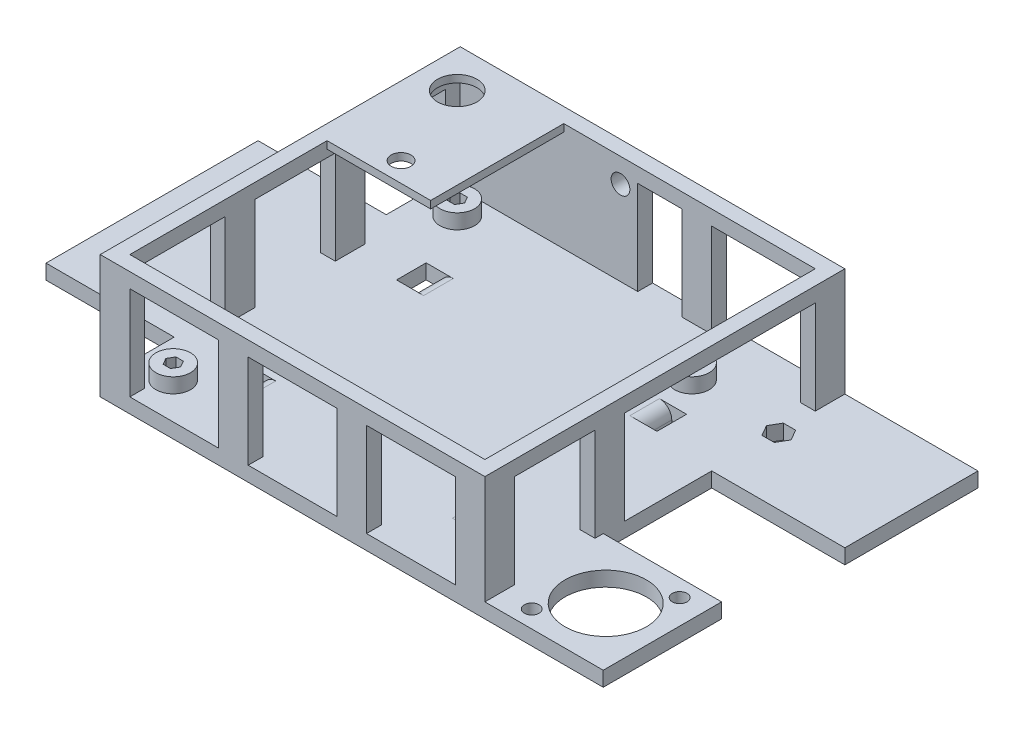
from build123d import *

# Parameters (mm, degrees)
BOSS_EXTRUDE1_DEPTH = 3
SKETCH2_W           = 3
SKETCH2_H           = 6
SKETCH2_W_2         = 6
SKETCH2_H_2         = 3
BOSS_EXTRUDE2_DEPTH = 19
SKETCH3_W           = 78
SKETCH3_H           = 73
SKETCH3_W_2         = 72
SKETCH3_H_2         = 67
BOSS_EXTRUDE3_DEPTH = 3
SKETCH4_R           = 3.5
BOSS_EXTRUDE4_DEPTH = 3
CUT_EXTRUDE1_DEPTH  = 130.761319352
CUT_EXTRUDE2_DEPTH  = 3
SKETCH7_R           = 1.9
CUT_EXTRUDE3_DEPTH  = 3
SKETCH8_W           = 21
SKETCH8_H           = 27
SKETCH8_R           = 2
SKETCH8_R_2         = 4
BOSS_EXTRUDE5_DEPTH = 1.5
SKETCH9_R           = 1.5
SKETCH9_R_2         = 8.25
CUT_EXTRUDE4_DEPTH  = 3
SKETCH10_W          = 3
SKETCH10_H          = 6
CUT_EXTRUDE5_DEPTH  = 3
FILLET1_R           = 2.5


with BuildPart() as part:
    # Sketch1 → Boss-Extrude1 (new body)
    with BuildSketch(Plane(origin=(0, 0, 0), x_dir=(1, 0, 0), z_dir=(0, 1, 0))):
        Polygon((100, 24), (102, 24), (102, 0), (100, 0), (78, 0), (0, 0), (0, 15), (-26, 15), (-26, 58), (0, 58), (0, 73), (78, 73), (105, 73), (105, 46), (78, 46), (78, 24), align=None)
    extrude(amount=BOSS_EXTRUDE1_DEPTH)

    # Sketch2 → Boss-Extrude2 (add)
    with BuildSketch(Plane(origin=(0, 3, 0), x_dir=(1, 0, 0), z_dir=(0, 1, 0))):
        Polygon((0, 0), (3, 0), (6, 0), (6, 3), (3, 3), (3, 6), (0, 6), align=None)
        Polygon((78, 0), (75, 0), (72, 0), (72, 3), (75, 3), (75, 6), (78, 6), align=None)
        with Locations((1.5, 25.3333)):
            Rectangle(SKETCH2_W, SKETCH2_H)
        with Locations((1.5, 47.6663)):
            Rectangle(SKETCH2_W, SKETCH2_H)
        Polygon((0, 73), (3, 73), (6, 73), (36, 73), (39, 73), (39, 70), (36, 70), (17, 70), (3, 70), (3, 67), (0, 67), align=None)
        with Locations((27, 1.5)):
            Rectangle(SKETCH2_W_2, SKETCH2_H_2)
        with Locations((51, 1.5)):
            Rectangle(SKETCH2_W_2, SKETCH2_H_2)
        with Locations((76.5, 25.333)):
            Rectangle(SKETCH2_W, SKETCH2_H)
        Polygon((72, 73), (78, 73), (78, 70), (78, 67), (75, 67), (75, 70), (72, 70), align=None)
        with Locations((51, 71.5)):
            Rectangle(SKETCH2_W_2, SKETCH2_H_2)
    extrude(amount=BOSS_EXTRUDE2_DEPTH)

    # Sketch3 → Boss-Extrude3 (add)
    with BuildSketch(Plane(origin=(0, 22, 0), x_dir=(1, 0, 0), z_dir=(0, 1, 0))):
        with Locations((39, 36.5)):
            Rectangle(SKETCH3_W, SKETCH3_H)
        with Locations((39, 36.5)):
            Rectangle(SKETCH3_W_2, SKETCH3_H_2, mode=Mode.SUBTRACT)
    extrude(amount=BOSS_EXTRUDE3_DEPTH)

    # Sketch4 → Boss-Extrude4 (add)
    # profile 1 of 4: a face of its own
    with BuildSketch(Plane(origin=(0, 3, 0), x_dir=(1, 0, 0), z_dir=(0, 1, 0))):
        with Locations((7.4, 65)):
            Circle(SKETCH4_R)
        Polygon((8.9, 65), (8.15, 66.299038106), (6.65, 66.299038106), (5.9, 65), (6.65, 63.700961894), (8.15, 63.700961894), align=None, mode=Mode.SUBTRACT)
    # profile 2 of 4: a face of its own
    with BuildSketch(Plane(origin=(0, 3, 0), x_dir=(1, 0, 0), z_dir=(0, 1, 0))):
        with Locations((7.4, 7.4)):
            Circle(SKETCH4_R)
        Polygon((8.9, 7.4), (8.15, 8.699038106), (6.65, 8.699038106), (5.9, 7.4), (6.65, 6.100961894), (8.15, 6.100961894), align=None, mode=Mode.SUBTRACT)
    # profile 3 of 4: a face of its own
    with BuildSketch(Plane(origin=(0, 3, 0), x_dir=(1, 0, 0), z_dir=(0, 1, 0))):
        with Locations((70.4, 7.4)):
            Circle(SKETCH4_R)
        Polygon((68.9, 7.4), (69.65, 6.100961894), (71.15, 6.100961894), (71.9, 7.4), (71.15, 8.699038106), (69.65, 8.699038106), align=None, mode=Mode.SUBTRACT)
    # profile 4 of 4: a face of its own
    with BuildSketch(Plane(origin=(0, 3, 0), x_dir=(1, 0, 0), z_dir=(0, 1, 0))):
        with Locations((60, 60)):
            Circle(SKETCH4_R)
    extrude(amount=BOSS_EXTRUDE4_DEPTH)

    # Sketch4_2 → Cut-Extrude1 (cut, through all)
    with BuildSketch(Plane(origin=(0, 3, 0), x_dir=(1, 0, 0), z_dir=(0, 1, 0))):
        Polygon((8.15, 63.700961894), (8.9, 65), (8.15, 66.299038106), (6.65, 66.299038106), (5.9, 65), (6.65, 63.700961894), align=None)
        Polygon((8.15, 6.100961894), (8.9, 7.4), (8.15, 8.699038106), (6.65, 8.699038106), (5.9, 7.4), (6.65, 6.100961894), align=None)
        Polygon((69.65, 8.699038106), (68.9, 7.4), (69.65, 6.100961894), (71.15, 6.100961894), (71.9, 7.4), (71.15, 8.699038106), align=None)
    extrude(amount=-CUT_EXTRUDE1_DEPTH, mode=Mode.SUBTRACT)

    # Sketch5 → Cut-Extrude2 (cut)
    with BuildSketch(Plane(origin=(0, 3, 0), x_dir=(1, 0, 0), z_dir=(0, 1, 0))):
        Polygon((80.601762475, 59.5), (79.351762475, 61.665063509), (76.851762475, 61.665063509), (75.601762475, 59.5), (76.851762475, 57.334936491), (79.351762475, 57.334936491), align=None)
    extrude(amount=-CUT_EXTRUDE2_DEPTH, mode=Mode.SUBTRACT)

    # Sketch7 → Cut-Extrude3 (cut)
    with BuildSketch(Plane(origin=(0, 0, -73), x_dir=(-1, 0, 0), z_dir=(0, 0, -1))):
        with Locations((-35.5, 20.1)):
            Circle(SKETCH7_R)
    extrude(amount=-CUT_EXTRUDE3_DEPTH, mode=Mode.SUBTRACT)

    # Sketch8 → Boss-Extrude5 (add)
    with BuildSketch(Plane(origin=(0, 25, 0), x_dir=(1, 0, 0), z_dir=(0, 1, 0))):
        with Locations((13.5, 56.5)):
            Rectangle(SKETCH8_W, SKETCH8_H)
        with Locations((14, 47)):
            Circle(SKETCH8_R, mode=Mode.SUBTRACT)
        with Locations((7.4, 65)):
            Circle(SKETCH8_R_2, mode=Mode.SUBTRACT)
    extrude(amount=-BOSS_EXTRUDE5_DEPTH)

    # Sketch9 → Cut-Extrude4 (cut)
    with BuildSketch(Plane(origin=(0, 3, 0), x_dir=(1, 0, 0), z_dir=(0, 1, 0))):
        with Locations((97, 20.5)):
            Circle(SKETCH9_R)
        with Locations((84, 3.5)):
            Circle(SKETCH9_R)
        with Locations((90.5, 12)):
            Circle(SKETCH9_R_2)
    extrude(amount=-CUT_EXTRUDE4_DEPTH, mode=Mode.SUBTRACT)

    # Sketch10 → Cut-Extrude5 (cut)
    with BuildSketch(Plane(origin=(0, 3, 0), x_dir=(1, 0, 0), z_dir=(0, 1, 0))):
        with Locations((64, 14.4)):
            Rectangle(SKETCH10_W, SKETCH10_H)
        with Locations((64, 50.4)):
            Rectangle(SKETCH10_W, SKETCH10_H)
        with Locations((14, 14.584176744)):
            Rectangle(SKETCH10_W, SKETCH10_H)
        with Locations((14, 50.584176744)):
            Rectangle(SKETCH10_W, SKETCH10_H)
    extrude(amount=-CUT_EXTRUDE5_DEPTH, mode=Mode.SUBTRACT)

    # Fillet1
    fillet1_edges = [part.edges().sort_by_distance(p)[0] for p in [
        (15.5, 3, -50.584176744),
        (62.5, 3, -50.4),
        (62.5, 3, -14.4),
        (15.5, 3, -14.584176744),
    ]]
    fillet(fillet1_edges, radius=FILLET1_R)


solid = part.part
